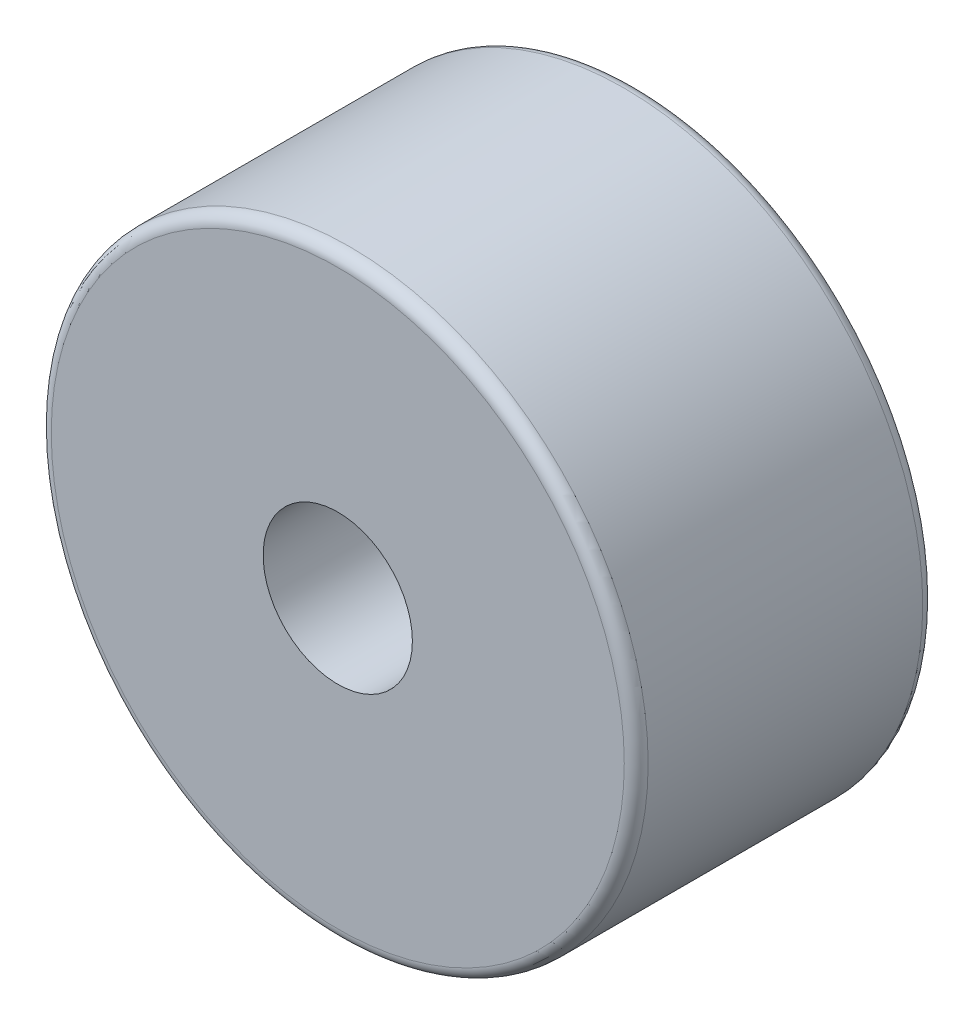
from build123d import *

# Parameters (mm, degrees)
FILLET1_R = 0.254


with BuildPart() as part:
    # Sketch1 → Revolve1 (revolve)
    with BuildSketch(Plane(origin=(0, 0, 0), x_dir=(1, 0, 0), z_dir=(0, 1, 0))):
        Polygon((-1.5875, 0), (-6.35, 0), (-6.35, 6.35), (-2.9718, 6.35), (-2.9718, 2.38125), (-1.5875, 2.38125), align=None)
    revolve(axis=Axis((0, 0, 0), (0, 0, -1)))

    # Fillet1
    fillet1_edges = [part.edges().sort_by_distance(p)[0] for p in [
        (6.35, 0, 0),
        (6.35, 0, -6.35),
    ]]
    fillet(fillet1_edges, radius=FILLET1_R)


solid = part.part
